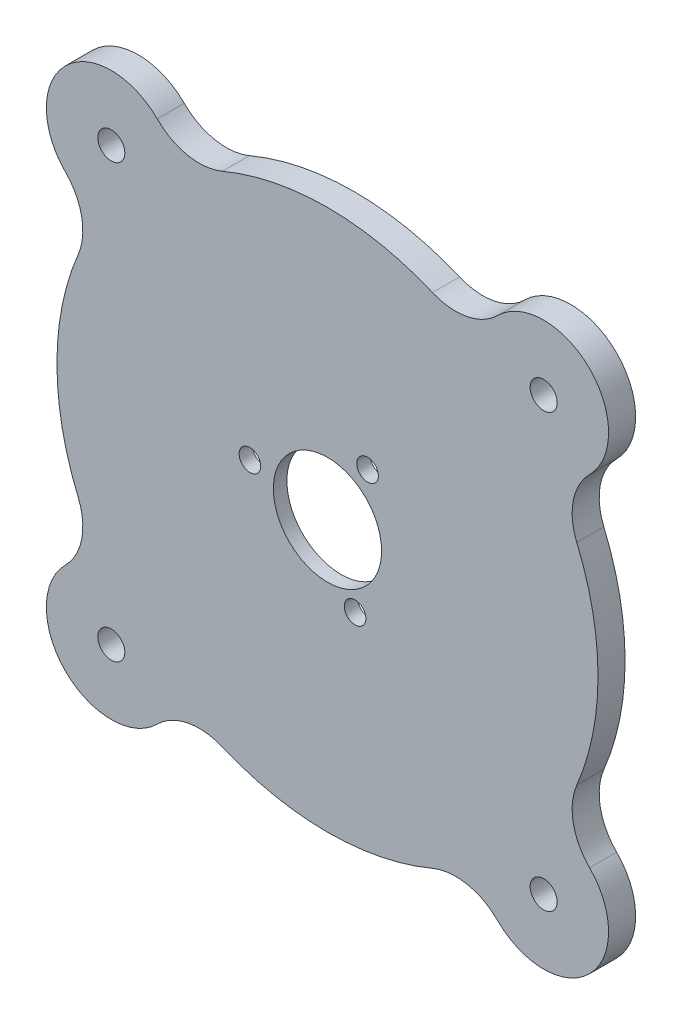
from build123d import *

# Parameters (mm, degrees)
SKETCH1_R               = 5
SKETCH1_R_2             = 4
BOSS_EXTRUDE1_DEPTH     = 10
CUT_EXTRUDE4_DEPTH      = 148.281004757
CUT_EXTRUDE4_DEPTH_BACK = 148.281004757
SKETCH3_R               = 20
SKETCH6_R               = 42.5
CUT_EXTRUDE5_DEPTH      = 5


with BuildPart() as part:
    # Sketch1 → Boss-Extrude1 (new body)
    with BuildSketch(Plane.XY):
        with BuildLine():
            ThreePointArc((62.932503526, 96.873629023), (51.59941337, 90.83800352), (38.827006486, 92.154563465))
            ThreePointArc((38.827006486, 92.154563465), (0, 100), (-38.827006486, 92.154563465))
            ThreePointArc((-38.827006486, 92.154563465), (-51.59941337, 90.83800352), (-62.932503526, 96.873629023))
            ThreePointArc((-62.932503526, 96.873629023), (-96.873629023, 96.873629023), (-96.873629023, 62.932503526))
            ThreePointArc((-96.873629023, 62.932503526), (-90.83800352, 51.59941337), (-92.154563465, 38.827006486))
            ThreePointArc((-92.154563465, 38.827006486), (-100, 0), (-92.154563465, -38.827006486))
            ThreePointArc((-92.154563465, -38.827006486), (-90.83800352, -51.59941337), (-96.873629023, -62.932503526))
            ThreePointArc((-96.873629023, -62.932503526), (-96.873629023, -96.873629023), (-62.932503526, -96.873629023))
            ThreePointArc((-62.932503526, -96.873629023), (-51.59941337, -90.83800352), (-38.827006486, -92.154563465))
            ThreePointArc((-38.827006486, -92.154563465), (0, -100), (38.827006486, -92.154563465))
            ThreePointArc((38.827006486, -92.154563465), (51.59941337, -90.83800352), (62.932503526, -96.873629023))
            ThreePointArc((62.932503526, -96.873629023), (96.873629023, -96.873629023), (96.873629023, -62.932503526))
            ThreePointArc((96.873629023, -62.932503526), (90.83800352, -51.59941337), (92.154563465, -38.827006486))
            ThreePointArc((92.154563465, -38.827006486), (100, 0), (92.154563465, 38.827006486))
            ThreePointArc((92.154563465, 38.827006486), (90.83800352, 51.59941337), (96.873629023, 62.932503526))
            ThreePointArc((96.873629023, 62.932503526), (96.873629023, 96.873629023), (62.932503526, 96.873629023))
        make_face()
        with Locations((-79.903066991, 79.903065557)):
            Circle(SKETCH1_R, mode=Mode.SUBTRACT)
        with Locations((-79.903066274, -79.903067707)):
            Circle(SKETCH1_R, mode=Mode.SUBTRACT)
        with Locations((79.903066274, 79.903066274)):
            Circle(SKETCH1_R, mode=Mode.SUBTRACT)
        with Locations((79.903066991, -79.903066991)):
            Circle(SKETCH1_R, mode=Mode.SUBTRACT)
        with Locations((-28.659563911, 4.801920664)):
            Circle(SKETCH1_R_2, mode=Mode.SUBTRACT)
        with Locations((10.214266366, -24.539516671)):
            Circle(SKETCH1_R_2, mode=Mode.SUBTRACT)
        with Locations((14.823001416, 23.464491412)):
            Circle(SKETCH1_R_2, mode=Mode.SUBTRACT)
    extrude(amount=BOSS_EXTRUDE1_DEPTH)

    # Sketch3 → Cut-Extrude4 (cut, two sides: drawn at the far end of the back side and taken through both)
    with BuildSketch(Plane.XY.offset(-CUT_EXTRUDE4_DEPTH_BACK)):
        Circle(SKETCH3_R)
    extrude(amount=CUT_EXTRUDE4_DEPTH + CUT_EXTRUDE4_DEPTH_BACK, mode=Mode.SUBTRACT)

    # Sketch6 → Cut-Extrude5 (cut)
    with BuildSketch(Plane.XY):
        with Locations((-0.919801826, 0.750296012)):
            Circle(SKETCH6_R)
    extrude(amount=CUT_EXTRUDE5_DEPTH, mode=Mode.SUBTRACT)


solid = part.part
